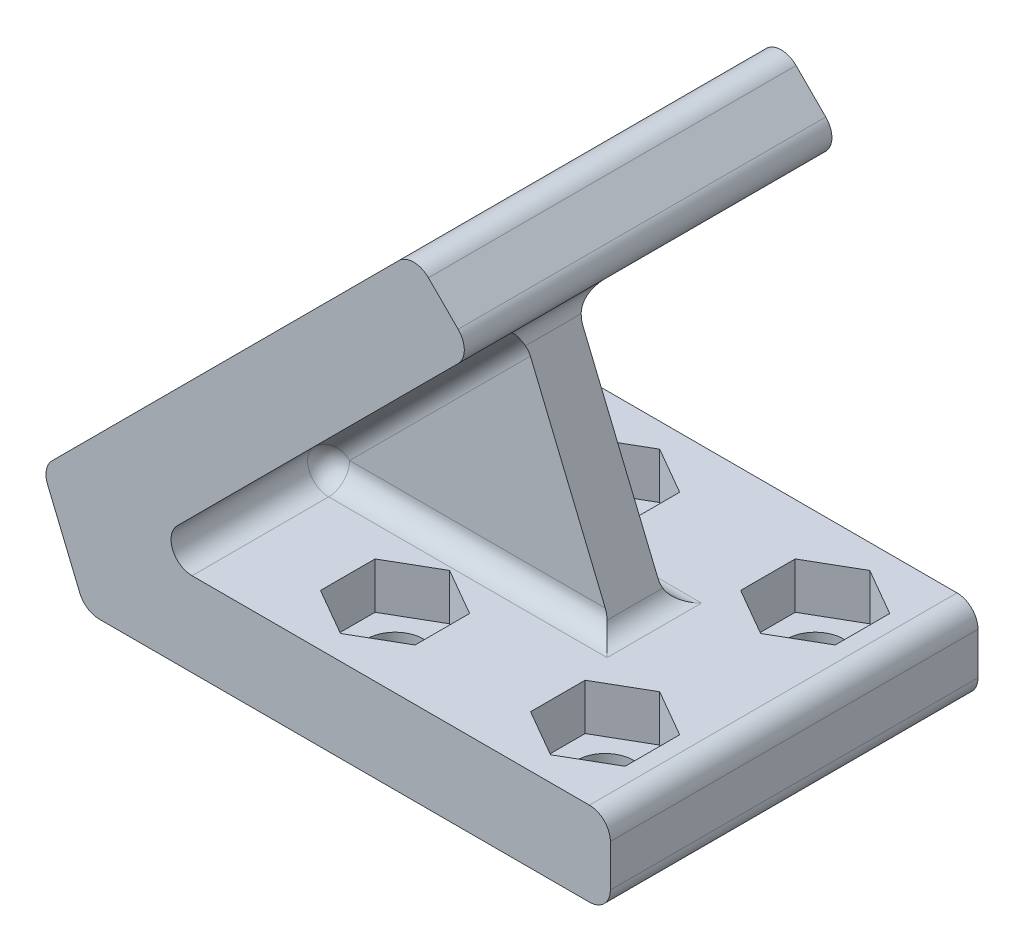
from build123d import *

# Parameters (mm, degrees)
BOSS_EXTRUDE1_DEPTH = 44.45
SKETCH2_R           = 3.429
CUT_EXTRUDE1_DEPTH  = 44.45
SKETCH3_R           = 3.429
CUT_EXTRUDE2_DEPTH  = 44.45
CUT_EXTRUDE3_DEPTH  = 5.588
CUT_EXTRUDE4_DEPTH  = 5.588
BOSS_EXTRUDE2_DEPTH = 3.175
FILLET1_R           = 2.54


with BuildPart() as part:
    # Sketch1 → Boss-Extrude1 (new body)
    with BuildSketch(Plane.XY):
        Polygon((0, 0), (63.5, 0), (63.5, 10.16), (6.788694961, 10.16), (46.889643324, 50.260948363), (39.705438427, 57.44515326), (-5.195842178, 12.543872654), align=None)
    extrude(amount=BOSS_EXTRUDE1_DEPTH)

    # Sketch2 → Cut-Extrude1 (cut)
    with BuildSketch(Plane(origin=(0, 10.16, 0), x_dir=(1, 0, 0), z_dir=(0, 1, 0))):
        with Locations((53.34, -34.925)):
            Circle(SKETCH2_R)
        with Locations((53.34, -9.525)):
            Circle(SKETCH2_R)
        with Locations((27.94, -9.525)):
            Circle(SKETCH2_R)
        with Locations((27.94, -34.925)):
            Circle(SKETCH2_R)
    extrude(amount=-CUT_EXTRUDE1_DEPTH, mode=Mode.SUBTRACT)

    # Sketch3 → Cut-Extrude2 (cut)
    with BuildSketch(Plane(origin=(-1.685652519, 1.685652519, 0), x_dir=(0, 0, -1), z_dir=(0.707106781, -0.707106781, 0))):
        with Locations((-9.525, 33.135842178)):
            Circle(SKETCH3_R)
        with Locations((-9.525, 58.535842178)):
            Circle(SKETCH3_R)
        with Locations((-34.925, 58.535842178)):
            Circle(SKETCH3_R)
        with Locations((-34.925, 33.135842178)):
            Circle(SKETCH3_R)
    extrude(amount=-CUT_EXTRUDE2_DEPTH, mode=Mode.SUBTRACT)

    # Sketch4 → Cut-Extrude3 (cut)
    with BuildSketch(Plane(origin=(0, 10.16, 0), x_dir=(1, 0, 0), z_dir=(0, 1, 0))):
        Polygon((22.225, -31.625443212), (22.225, -38.224556788), (27.94, -41.524113577), (33.655, -38.224556788), (33.655, -31.625443212), (27.94, -28.325886423), align=None)
        Polygon((47.625, -31.625443212), (47.625, -38.224556788), (53.34, -41.524113577), (59.055, -38.224556788), (59.055, -31.625443212), (53.34, -28.325886423), align=None)
        Polygon((22.225, -6.225443212), (22.225, -12.824556788), (27.94, -16.124113577), (33.655, -12.824556788), (33.655, -6.225443212), (27.94, -2.925886423), align=None)
        Polygon((47.625, -6.225443212), (47.625, -12.824556788), (53.34, -16.124113577), (59.055, -12.824556788), (59.055, -6.225443212), (53.34, -2.925886423), align=None)
    extrude(amount=-CUT_EXTRUDE3_DEPTH, mode=Mode.SUBTRACT)

    # Sketch5 → Cut-Extrude4 (cut)
    with BuildSketch(Plane(origin=(-1.685652519, 1.685652519, 0), x_dir=(0, 0, -1), z_dir=(0.707106781, -0.707106781, 0))):
        Polygon((-2.925886423, 58.535842178), (-6.225443212, 64.250842178), (-12.824556788, 64.250842178), (-16.124113577, 58.535842178), (-12.824556788, 52.820842178), (-6.225443212, 52.820842178), align=None)
        Polygon((-28.325886423, 58.535842178), (-31.625443212, 64.250842178), (-38.224556788, 64.250842178), (-41.524113577, 58.535842178), (-38.224556788, 52.820842178), (-31.625443212, 52.820842178), align=None)
        Polygon((-2.925886423, 33.135842178), (-6.225443212, 38.850842178), (-12.824556788, 38.850842178), (-16.124113577, 33.135842178), (-12.824556788, 27.420842178), (-6.225443212, 27.420842178), align=None)
        Polygon((-28.325886423, 33.135842178), (-31.625443212, 38.850842178), (-38.224556788, 38.850842178), (-41.524113577, 33.135842178), (-38.224556788, 27.420842178), (-31.625443212, 27.420842178), align=None)
    extrude(amount=-CUT_EXTRUDE4_DEPTH, mode=Mode.SUBTRACT)

    # Sketch6 → Boss-Extrude2 (add, symmetric)
    with BuildSketch(Plane.XY.offset(22.225)):
        Polygon((6.788694961, 10.16), (33.729463324, 37.100768363), (44.888694961, 10.16), align=None)
    extrude(amount=BOSS_EXTRUDE2_DEPTH, both=True)

    # Fillet1
    fillet1_edges = [part.edges().sort_by_distance(p)[0] for p in [
        (-5.195842178, 12.543872654, 22.225),
        (39.705438427, 57.44515326, 22.225),
        (46.889643324, 50.260948363, 22.225),
        (6.788694961, 10.16, 34.925),
        (63.5, 10.16, 22.225),
        (63.5, 0, 22.225),
        (0, 0, 22.225),
        (6.788694961, 10.16, 9.525),
        (25.838694961, 10.16, 19.05),
        (44.888694961, 10.16, 22.225),
        (20.259079143, 23.630384182, 19.05),
        (33.729463324, 37.100768363, 22.225),
        (25.838694961, 10.16, 25.4),
        (20.259079143, 23.630384182, 25.4),
    ]]
    fillet(fillet1_edges, radius=FILLET1_R)


solid = part.part
